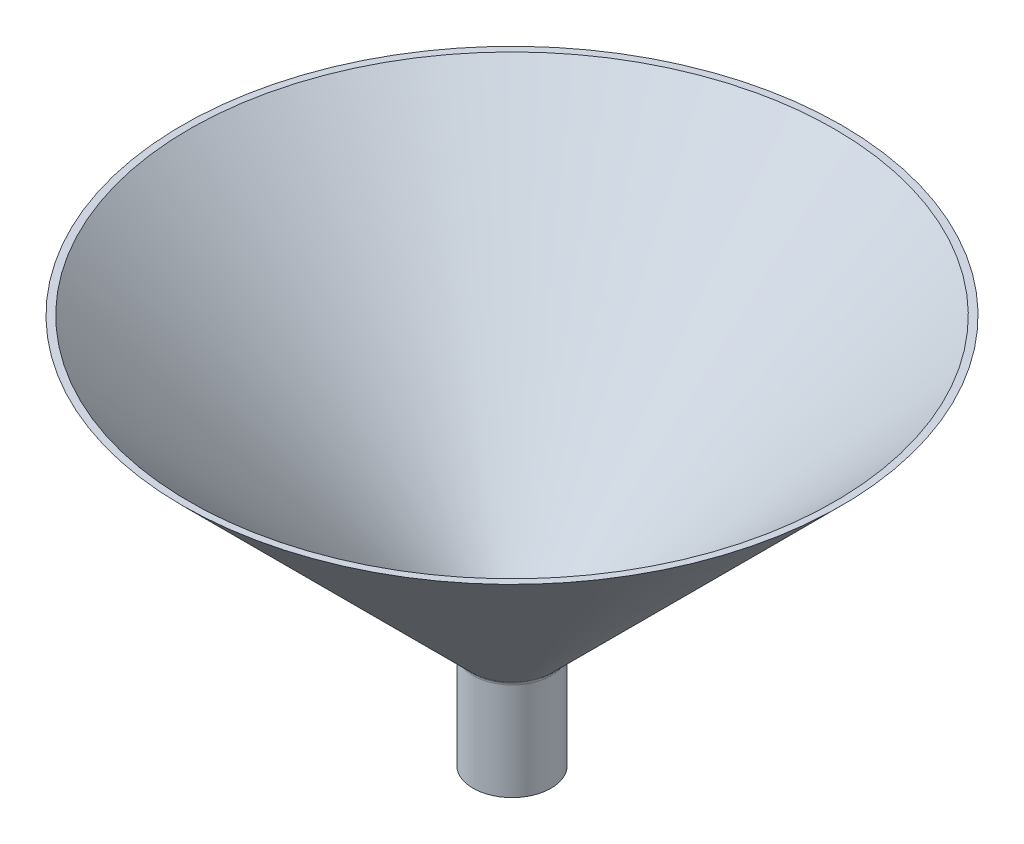
from build123d import *
from build123d.topology import SkipClean

# Parameters (mm, degrees)
SKETCH3_R          = 20.5
CUT_EXTRUDE1_DEPTH = 2.5


with BuildPart() as part:
    # Sketch2 → Revolve1 (revolve)
    with BuildSketch(Plane.XY, mode=Mode.PRIVATE) as revolve1_sk:
        with BuildLine():
            Line((-12, 0), (-10.5, 0))
            Line((-10.5, 0), (-10.5, 30))
            ThreePointArc((-10.5, 30), (-10.728361402, 31.148050297), (-11.378679656, 32.121320344))
            Line((-11.378679656, 32.121320344), (-99.257359313, 120))
            Line((-99.257359313, 120), (-101.378679656, 120))
            Line((-101.378679656, 120), (-12.43972081, 31.061041153))
            Line((-12.43972081, 31.061041153), (-12.439339828, 31.060660172))
            ThreePointArc((-12.439339828, 31.060660172), (-12.114180701, 30.574025149), (-12, 30))
            Line((-12, 30), (-12, 0))
        make_face()
    revolve(revolve1_sk.sketch.rotate(Axis((0, 0, 0), (0, 1, 0)), 270), axis=Axis((0, 0, 0), (0, 1, 0)))

    # Sketch3 → Cut-Extrude1 (cut, symmetric)
    with SkipClean():  # the faces are left unmerged after this step: merging them gives an invalid solid
        with BuildSketch(Plane(origin=(0, 0, 0), x_dir=(0, 0, -1), z_dir=(1, 0, 0))):
            with Locations((25, 20)):
                Circle(SKETCH3_R)
        extrude(amount=CUT_EXTRUDE1_DEPTH, both=True, mode=Mode.SUBTRACT)


solid = part.part
